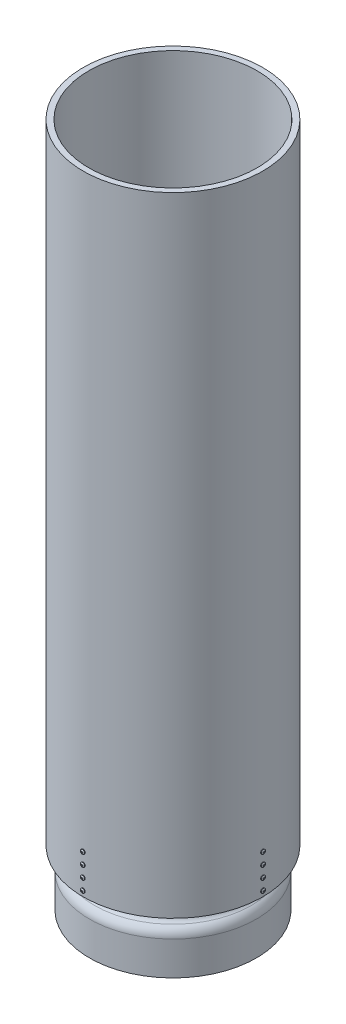
from build123d import *

# Parameters (mm, degrees)
SKETCH2_W           = 12.7
SKETCH2_H           = 1422.4
BOSS_EXTRUDE1_DEPTH = 101.6
SKETCH4_R           = 2.5527
CUT_EXTRUDE1_DEPTH  = 25.4
CIRPATTERN1_COUNT   = 4
CIRPATTERN2_COUNT   = 4
CUT_EXTRUDE2_DEPTH  = 1.5875
LPATTERN1_COUNT     = 4
LPATTERN1_PITCH     = 25.4
CIRPATTERN3_COUNT   = 4


with BuildPart() as part:
    # Sketch2 → Revolve1 (revolve)
    with BuildSketch(Plane.XY, mode=Mode.PRIVATE) as revolve1_sk:
        with BuildLine():
            Line((-177.8, 0), (-177.8, 76.2))
            ThreePointArc((-177.8, 76.2), (-175.739444065, 84.42915702), (-170.044062963, 90.716250952))
            ThreePointArc((-170.044062963, 90.716250952), (-161.759872268, 99.861114853), (-158.7627, 111.830797791))
            Line((-158.7627, 111.830797791), (-158.7627, 228.6))
            Line((-158.7627, 228.6), (-169.8625, 228.6))
            Line((-169.8625, 228.6), (-169.8625, 111.830797791))
            ThreePointArc((-169.8625, 111.830797791), (-171.923055935, 103.601640771), (-177.618437037, 97.314546839))
            ThreePointArc((-177.618437037, 97.314546839), (-185.902627732, 88.169682938), (-188.8998, 76.2))
            Line((-188.8998, 76.2), (-188.8998, 0))
            Line((-188.8998, 0), (-177.8, 0))
        make_face()
        with Locations((-196.85, 838.2)):
            Rectangle(SKETCH2_W, SKETCH2_H)
    revolve(revolve1_sk.sketch.rotate(Axis((0, -96.465125913, 0), (0, 1, 0)), 270), axis=Axis((0, -96.465125913, 0), (0, 1, 0)))


with BuildPart() as body_2:
    # Sketch3 → Boss-Extrude1 (new body)
    with BuildSketch(Plane.XZ.offset(-127)):
        with BuildLine():
            Line((-9.525, 190.261725986), (-9.525, 169.595233663))
            ThreePointArc((-9.525, 169.595233663), (0, 169.8625), (9.525, 169.595233663))
            Line((9.525, 169.595233663), (9.525, 190.261725986))
            ThreePointArc((9.525, 190.261725986), (0, 190.5), (-9.525, 190.261725986))
        make_face()
    extrude(amount=-BOSS_EXTRUDE1_DEPTH)


with BuildPart() as cut_extrude1_tool:
    # Sketch4 → Cut-Extrude1 (new body)
    with BuildSketch(Plane.XY.offset(203.2)):
        with Locations((0, 139.7)):
            Circle(SKETCH4_R)
        with Locations((0, 165.1)):
            Circle(SKETCH4_R)
        with Locations((0, 190.5)):
            Circle(SKETCH4_R)
        with Locations((0, 215.9)):
            Circle(SKETCH4_R)
    cut_extrude1 = extrude(amount=-CUT_EXTRUDE1_DEPTH)


with BuildPart() as part_1:
    add(part.part)

    # Cut-Extrude1: cut by cut_extrude1_tool
    add(cut_extrude1_tool.part, mode=Mode.SUBTRACT)

    # CirPattern2: Cut-Extrude1 ×4 about axis
    cirpattern2_axis = Axis((0, 127, 0), (0, -1, 0))
    for i in range(1, CIRPATTERN2_COUNT):
        add(cut_extrude1.rotate(cirpattern2_axis, i * 360 / CIRPATTERN2_COUNT), mode=Mode.SUBTRACT)


with BuildPart() as body_2_1:
    add(body_2.part)

    # Cut-Extrude1: cut by cut_extrude1_tool
    add(cut_extrude1_tool.part, mode=Mode.SUBTRACT)


with BuildPart() as cirpattern1_1:
    # CirPattern1: pattern copy
    add(body_2_1.part.rotate(Axis((0, 0, 0), (0, 1, 0)), 1 * 360 / CIRPATTERN1_COUNT))


with BuildPart() as cirpattern1_2:
    # CirPattern1: pattern copy
    add(body_2_1.part.rotate(Axis((0, 0, 0), (0, 1, 0)), 2 * 360 / CIRPATTERN1_COUNT))


with BuildPart() as cirpattern1_3:
    # CirPattern1: pattern copy
    add(body_2_1.part.rotate(Axis((0, 0, 0), (0, 1, 0)), 3 * 360 / CIRPATTERN1_COUNT))


with BuildPart() as body_6:
    # Sketch6 → Revolve2 (revolve)
    with BuildSketch(Plane(origin=(0, 0, 0), x_dir=(0, 0, -1), z_dir=(1, 0, 0)), mode=Mode.PRIVATE) as revolve2_sk:
        with BuildLine():
            Line((-203.2, 215.9), (-203.2, 211.1629))
            Line((-203.2, 211.1629), (-204.7875, 211.1629))
            ThreePointArc((-204.7875, 211.1629), (-206.115582066, 213.367870318), (-206.5782, 215.9))
            Line((-206.5782, 215.9), (-203.2, 215.9))
        make_face()
    revolve(revolve2_sk.sketch.rotate(Axis((0, 215.9, 226.844724076), (0, 0, -1)), 180), axis=Axis((0, 215.9, 226.844724076), (0, 0, -1)))

    # Sketch7 → Cut-Extrude2 (cut)
    with BuildSketch(Plane.XY.offset(206.5782)):
        Polygon((2.38125, 216.296875), (0.396875, 216.296875), (0.396875, 218.28125), (-0.396875, 218.28125), (-0.396875, 216.296875), (-2.38125, 216.296875), (-2.38125, 215.503125), (-0.396875, 215.503125), (-0.396875, 213.51875), (0.396875, 213.51875), (0.396875, 215.503125), (2.38125, 215.503125), align=None)
    extrude(amount=-CUT_EXTRUDE2_DEPTH, mode=Mode.SUBTRACT)


with BuildPart() as lpattern1_1:
    # LPattern1: pattern copy
    add(body_6.part.moved(Location(Vector(0, -1, 0) * (1 * LPATTERN1_PITCH))))


with BuildPart() as lpattern1_2:
    # LPattern1: pattern copy
    add(body_6.part.moved(Location(Vector(0, -1, 0) * (2 * LPATTERN1_PITCH))))


with BuildPart() as lpattern1_3:
    # LPattern1: pattern copy
    add(body_6.part.moved(Location(Vector(0, -1, 0) * (3 * LPATTERN1_PITCH))))


with BuildPart() as cirpattern3_1:
    # CirPattern3: pattern copy
    add(lpattern1_1.part.rotate(Axis((0, 0, 0), (0, 1, 0)), 1 * 360 / CIRPATTERN3_COUNT))


with BuildPart() as cirpattern3_2:
    # CirPattern3: pattern copy
    add(lpattern1_1.part.rotate(Axis((0, 0, 0), (0, 1, 0)), 2 * 360 / CIRPATTERN3_COUNT))


with BuildPart() as cirpattern3_3:
    # CirPattern3: pattern copy
    add(lpattern1_1.part.rotate(Axis((0, 0, 0), (0, 1, 0)), 3 * 360 / CIRPATTERN3_COUNT))


with BuildPart() as cirpattern3_4:
    # CirPattern3: pattern copy
    add(lpattern1_3.part.rotate(Axis((0, 0, 0), (0, 1, 0)), 1 * 360 / CIRPATTERN3_COUNT))


with BuildPart() as cirpattern3_5:
    # CirPattern3: pattern copy
    add(lpattern1_3.part.rotate(Axis((0, 0, 0), (0, 1, 0)), 2 * 360 / CIRPATTERN3_COUNT))


with BuildPart() as cirpattern3_6:
    # CirPattern3: pattern copy
    add(lpattern1_3.part.rotate(Axis((0, 0, 0), (0, 1, 0)), 3 * 360 / CIRPATTERN3_COUNT))


with BuildPart() as cirpattern3_7:
    # CirPattern3: pattern copy
    add(lpattern1_2.part.rotate(Axis((0, 0, 0), (0, 1, 0)), 1 * 360 / CIRPATTERN3_COUNT))


with BuildPart() as cirpattern3_8:
    # CirPattern3: pattern copy
    add(lpattern1_2.part.rotate(Axis((0, 0, 0), (0, 1, 0)), 2 * 360 / CIRPATTERN3_COUNT))


with BuildPart() as cirpattern3_9:
    # CirPattern3: pattern copy
    add(lpattern1_2.part.rotate(Axis((0, 0, 0), (0, 1, 0)), 3 * 360 / CIRPATTERN3_COUNT))


with BuildPart() as cirpattern3_10:
    # CirPattern3: pattern copy
    add(body_6.part.rotate(Axis((0, 0, 0), (0, 1, 0)), 1 * 360 / CIRPATTERN3_COUNT))


with BuildPart() as cirpattern3_11:
    # CirPattern3: pattern copy
    add(body_6.part.rotate(Axis((0, 0, 0), (0, 1, 0)), 2 * 360 / CIRPATTERN3_COUNT))


with BuildPart() as cirpattern3_12:
    # CirPattern3: pattern copy
    add(body_6.part.rotate(Axis((0, 0, 0), (0, 1, 0)), 3 * 360 / CIRPATTERN3_COUNT))


solid = Compound([part_1.part, body_2_1.part, cirpattern1_1.part, cirpattern1_2.part, cirpattern1_3.part, body_6.part, lpattern1_1.part, lpattern1_2.part, lpattern1_3.part, cirpattern3_1.part, cirpattern3_2.part, cirpattern3_3.part, cirpattern3_4.part, cirpattern3_5.part, cirpattern3_6.part, cirpattern3_7.part, cirpattern3_8.part, cirpattern3_9.part, cirpattern3_10.part, cirpattern3_11.part, cirpattern3_12.part])
